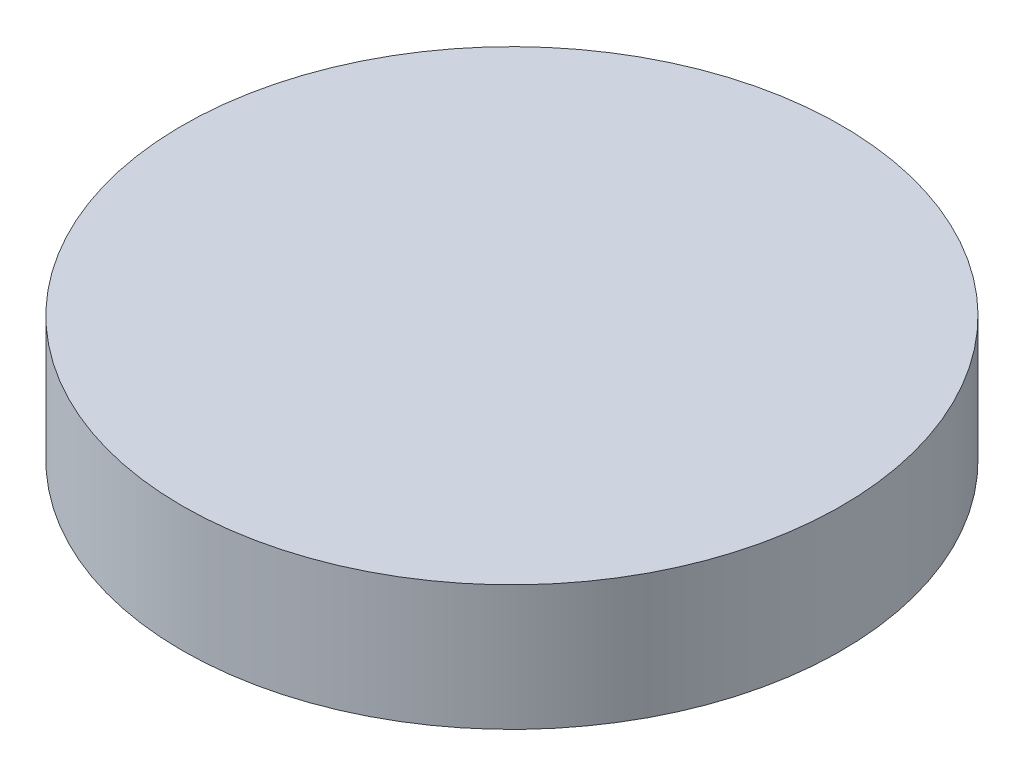
from build123d import *

# Parameters (mm, degrees)
SKETCH1_R      = 150
EXTRUDE1_DEPTH = 57


with BuildPart() as part:
    # Sketch1 → Extrude1 (new body)
    with BuildSketch(Plane(origin=(0, 0, 0), x_dir=(1, 0, 0), z_dir=(0, 1, 0))):
        with Locations(Location((0, 0, 0), (0, 0, 270))):  # turned: the seam where the file's is
            Circle(SKETCH1_R)
    extrude(amount=EXTRUDE1_DEPTH)


solid = part.part
